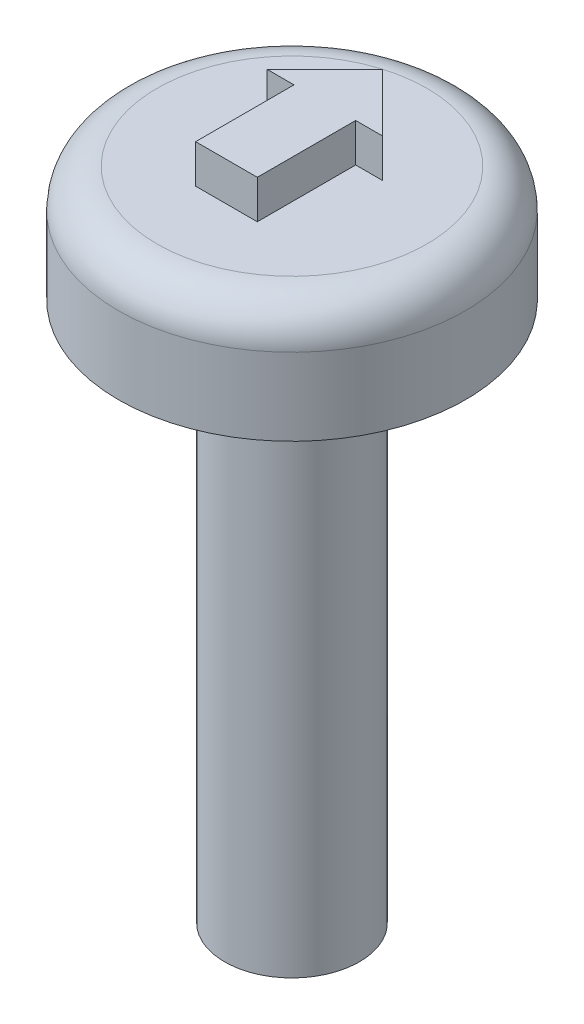
from build123d import *

# Parameters (mm, degrees)
SKETCH1_R           = 4.5
BOSS_EXTRUDE1_DEPTH = 3
FILLET1_R           = 1
BOSS_EXTRUDE2_DEPTH = 1
SKETCH6_R           = 1.75
BOSS_EXTRUDE3_DEPTH = 14


with BuildPart() as part:
    # Sketch1 → Boss-Extrude1 (new body)
    with BuildSketch(Plane(origin=(0, 115.601531763, -5.053e-06), x_dir=(1, 0, 0), z_dir=(0, 1, -4.4e-08))):
        with Locations((40.91030477, -143.155151275)):
            Circle(SKETCH1_R)
    extrude(amount=BOSS_EXTRUDE1_DEPTH)

    # Fillet1
    fillet1_edges = [part.edges().sort_by_distance(p)[0] for p in [
        (36.41030477, 118.601538021, 143.155146091),
    ]]
    fillet(fillet1_edges, radius=FILLET1_R)

    # Sketch2 → Boss-Extrude2 (add)
    with BuildSketch(Plane(origin=(0, 118.601531763, -5.184e-06), x_dir=(1, 0, 0), z_dir=(0, 1, -4.4e-08))):
        Polygon((40.11030477, -142.303288868), (40.11030477, -144.855151275), (41.71030477, -144.855151275), (41.71030477, -142.303288868), (42.41030477, -142.303288868), (40.91030477, -140.803288868), (39.41030477, -142.303288868), align=None)
    extrude(amount=BOSS_EXTRUDE2_DEPTH)

    # Sketch6 → Boss-Extrude3 (add)
    with BuildSketch(Plane(origin=(0, 115.601531763, -5.053e-06), x_dir=(-1, 0, 0), z_dir=(0, -1, 4.4e-08))):
        with Locations((-40.91030477, -143.155151275)):
            Circle(SKETCH6_R)
    extrude(amount=BOSS_EXTRUDE3_DEPTH)


solid = part.part
